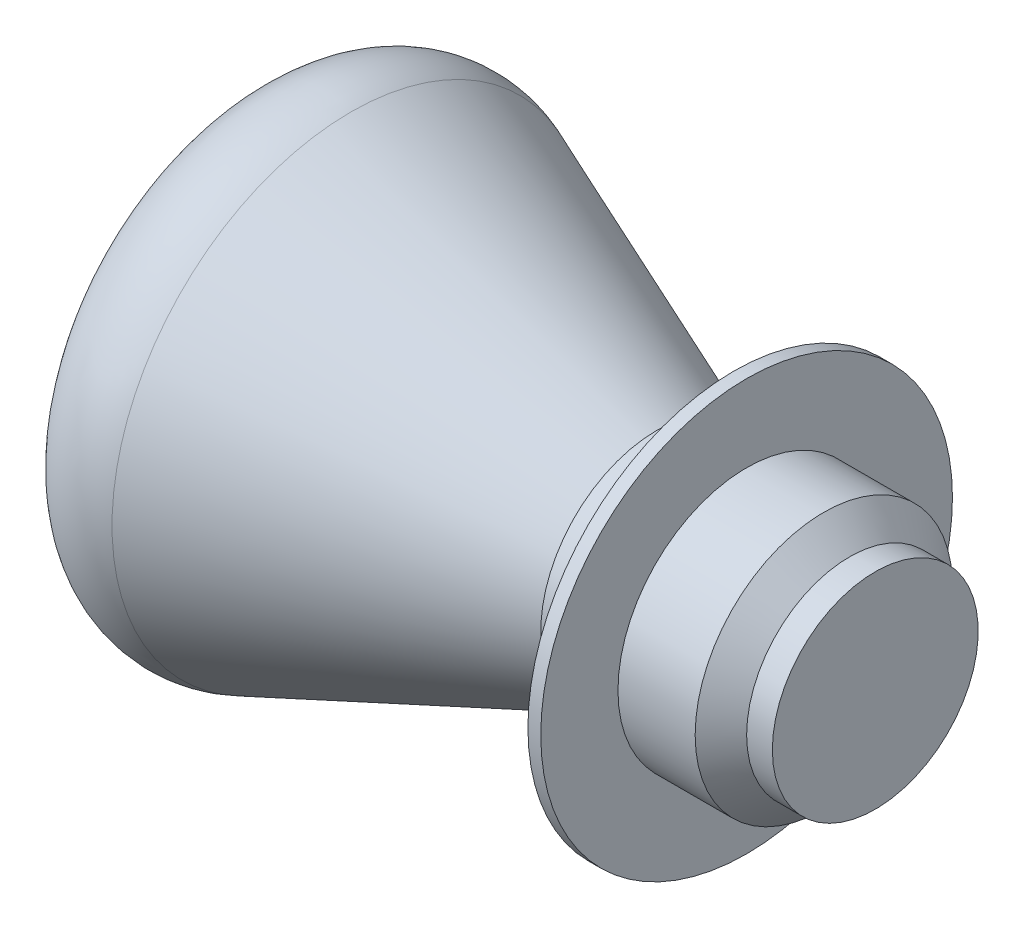
from build123d import *


with BuildPart() as part:
    # Sketch1 → Revolve1 (revolve)
    with BuildSketch(Plane.XY):
        Polygon((0, 4.5), (0, 0), (5.5, 0), (5.5, 4), (4.5, 4), (3.5, 5), (0.5, 5), (0.5, 8), (0, 8), (0, 5), (-2, 5), (-2, 4.5), align=None)
    revolve(axis=Axis((0, 0, 0), (1, 0, 0)))


with BuildPart() as body_2:
    # Sketch2 → Revolve2 (revolve)
    with BuildSketch(Plane.XY):
        with BuildLine():
            Line((0, 0), (0, 4.5))
            Line((0, 4.5), (-3, 4.5))
            Line((-3, 4.5), (-14.879552076, 9.282911506))
            ThreePointArc((-14.879552076, 9.282911506), (-17.339156162, 9.184522448), (-18.897161062, 7.278753994))
            ThreePointArc((-18.897161062, 7.278753994), (-19.617023423, 3.670972882), (-19.858362338, 0))
            Line((-19.858362338, 0), (0, 0))
        make_face()
    revolve(axis=Axis((0, 0, 0), (-1, 0, 0)))


solid = Compound([part.part, body_2.part])
